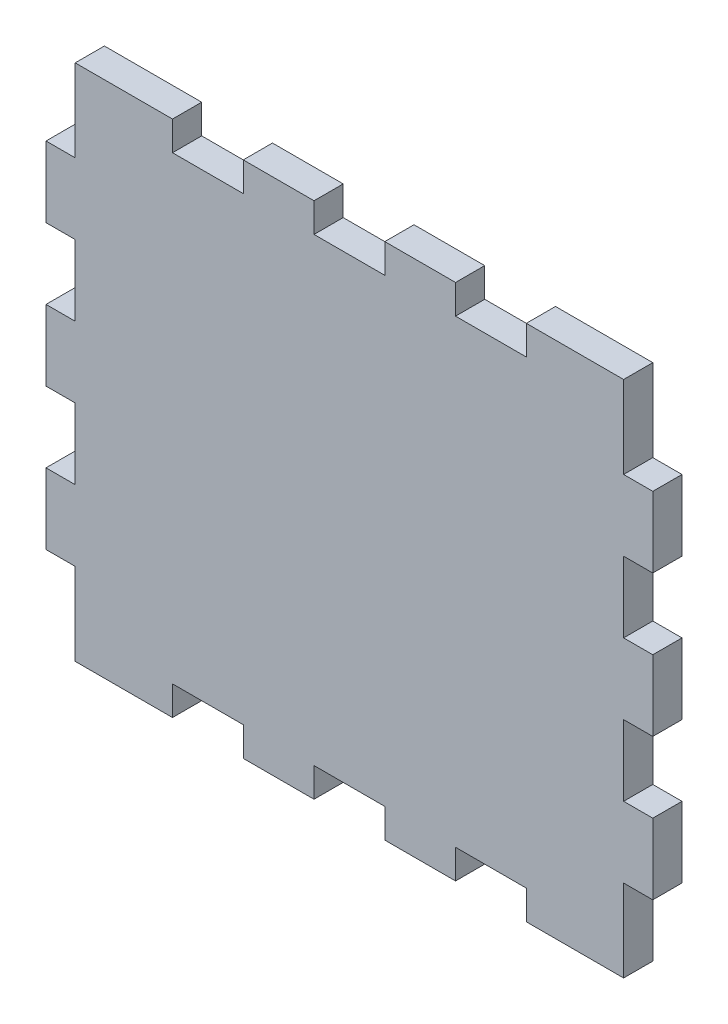
from build123d import *

# Parameters (mm, degrees)
ESQUISSE1_W                    = 62
ESQUISSE1_H                    = 52
BOSS_EXTRU_1_DEPTH             = 3.3
ESQUISSE2_W                    = 8
ESQUISSE2_H                    = 3.3
BOSS_EXTRU_2_DEPTH             = 3.3
R_P_TITION_LIN_AIRE1_COUNT     = 2
R_P_TITION_LIN_AIRE1_PITCH     = 16
R_P_TITION_LIN_AIRE1_COL_COUNT = 3
R_P_TITION_LIN_AIRE1_COL_PITCH = 16
SYM_TRIE1_COPY_1_SKETCH_W      = 8
SYM_TRIE1_COPY_1_SKETCH_H      = 3.3
SYM_TRIE1_COPY_1_DEPTH         = 3.3
SYM_TRIE1_COPY_2_SKETCH_W      = 8
SYM_TRIE1_COPY_2_SKETCH_H      = 3.3
SYM_TRIE1_COPY_2_DEPTH         = 3.3
SYM_TRIE1_COPY_3_SKETCH_W      = 8
SYM_TRIE1_COPY_3_SKETCH_H      = 3.3
SYM_TRIE1_COPY_3_DEPTH         = 3.3
ESQUISSE3_W                    = 3
ESQUISSE3_H                    = 3.3
BOSS_EXTRU_3_DEPTH             = 3.3
ESQUISSE4_W                    = 3.3
ESQUISSE4_H                    = 8
BOSS_EXTRU_4_DEPTH             = 3.3
R_P_TITION_LIN_AIRE2_COUNT     = 2
R_P_TITION_LIN_AIRE2_PITCH     = 16
R_P_TITION_LIN_AIRE2_COL_COUNT = 2
R_P_TITION_LIN_AIRE2_COL_PITCH = 16
SYM_TRIE3_COPY_1_SKETCH_W      = 3.3
SYM_TRIE3_COPY_1_SKETCH_H      = 8
SYM_TRIE3_COPY_1_DEPTH         = 3.3
SYM_TRIE3_COPY_2_SKETCH_W      = 3.3
SYM_TRIE3_COPY_2_SKETCH_H      = 8
SYM_TRIE3_COPY_2_DEPTH         = 3.3


with BuildPart() as part:
    # Esquisse1 → Boss.-Extru.1 (new body)
    with BuildSketch(Plane.XY):
        Rectangle(ESQUISSE1_W, ESQUISSE1_H)
    extrude(amount=BOSS_EXTRU_1_DEPTH)

    # Esquisse2 → Boss.-Extru.2 (add)
    with BuildSketch(Plane.XY.offset(3.3)):
        with Locations((8, -27.65)):
            Rectangle(ESQUISSE2_W, ESQUISSE2_H)
    boss_extru_2 = extrude(amount=-BOSS_EXTRU_2_DEPTH)

    # Répétition linéaire1: Boss.-Extru.2 ×2
    with Locations(*[(i * R_P_TITION_LIN_AIRE1_PITCH, 0, 0) for i in range(1, R_P_TITION_LIN_AIRE1_COUNT)]):
        add(boss_extru_2)

    # Répétition linéaire1 col: Boss.-Extru.2 ×3
    with Locations(*[(-i * R_P_TITION_LIN_AIRE1_COL_PITCH, 0, 0) for i in range(1, R_P_TITION_LIN_AIRE1_COL_COUNT)]):
        add(boss_extru_2)

    # Symétrie1: Boss.-Extru.2 across plane
    add(boss_extru_2.mirror(Plane.ZX))

    # Symétrie1 copy 1 sketch → Symétrie1 copy 1 (add)
    with BuildSketch(Plane(origin=(16, 0, 3.3), x_dir=(1, 0, 0), z_dir=(0, 0, 1))):
        with Locations((8, 27.65)):
            Rectangle(SYM_TRIE1_COPY_1_SKETCH_W, SYM_TRIE1_COPY_1_SKETCH_H)
    extrude(amount=-SYM_TRIE1_COPY_1_DEPTH)

    # Symétrie1 copy 2 sketch → Symétrie1 copy 2 (add)
    with BuildSketch(Plane(origin=(-16, 0, 3.3), x_dir=(1, 0, 0), z_dir=(0, 0, 1))):
        with Locations((8, 27.65)):
            Rectangle(SYM_TRIE1_COPY_2_SKETCH_W, SYM_TRIE1_COPY_2_SKETCH_H)
    extrude(amount=-SYM_TRIE1_COPY_2_DEPTH)

    # Symétrie1 copy 3 sketch → Symétrie1 copy 3 (add)
    with BuildSketch(Plane(origin=(-32, 0, 3.3), x_dir=(1, 0, 0), z_dir=(0, 0, 1))):
        with Locations((8, 27.65)):
            Rectangle(SYM_TRIE1_COPY_3_SKETCH_W, SYM_TRIE1_COPY_3_SKETCH_H)
    extrude(amount=-SYM_TRIE1_COPY_3_DEPTH)

    # Esquisse3 → Boss.-Extru.3 (add)
    with BuildSketch(Plane.XY.offset(3.3)):
        with Locations((-29.5, 27.65)):
            Rectangle(ESQUISSE3_W, ESQUISSE3_H)
        with Locations((29.5, 27.65)):
            Rectangle(ESQUISSE3_W, ESQUISSE3_H)
    boss_extru_3 = extrude(amount=-BOSS_EXTRU_3_DEPTH)

    # Symétrie2: Boss.-Extru.3 across plane
    add(boss_extru_3.mirror(Plane.ZX))

    # Esquisse4 → Boss.-Extru.4 (add)
    with BuildSketch(Plane.XY.offset(3.3)):
        with Locations((-32.65, 0)):
            Rectangle(ESQUISSE4_W, ESQUISSE4_H)
    boss_extru_4 = extrude(amount=-BOSS_EXTRU_4_DEPTH)

    # Répétition linéaire2: Boss.-Extru.4 ×2
    with Locations(*[(0, i * R_P_TITION_LIN_AIRE2_PITCH, 0) for i in range(1, R_P_TITION_LIN_AIRE2_COUNT)]):
        add(boss_extru_4)

    # Répétition linéaire2 col: Boss.-Extru.4 ×2
    with Locations(*[(0, -i * R_P_TITION_LIN_AIRE2_COL_PITCH, 0) for i in range(1, R_P_TITION_LIN_AIRE2_COL_COUNT)]):
        add(boss_extru_4)

    # Symétrie3: Boss.-Extru.4 across plane
    add(boss_extru_4.mirror(Plane(origin=(0, 0, 0), x_dir=(0, 0, 1), z_dir=(1, 0, 0))))

    # Symétrie3 copy 1 sketch → Symétrie3 copy 1 (add)
    with BuildSketch(Plane(origin=(0, 16, 3.3), x_dir=(-1, 0, 0), z_dir=(0, 0, 1))):
        with Locations((-32.65, 0)):
            Rectangle(SYM_TRIE3_COPY_1_SKETCH_W, SYM_TRIE3_COPY_1_SKETCH_H)
    extrude(amount=-SYM_TRIE3_COPY_1_DEPTH)

    # Symétrie3 copy 2 sketch → Symétrie3 copy 2 (add)
    with BuildSketch(Plane(origin=(0, -16, 3.3), x_dir=(-1, 0, 0), z_dir=(0, 0, 1))):
        with Locations((-32.65, 0)):
            Rectangle(SYM_TRIE3_COPY_2_SKETCH_W, SYM_TRIE3_COPY_2_SKETCH_H)
    extrude(amount=-SYM_TRIE3_COPY_2_DEPTH)


solid = part.part
